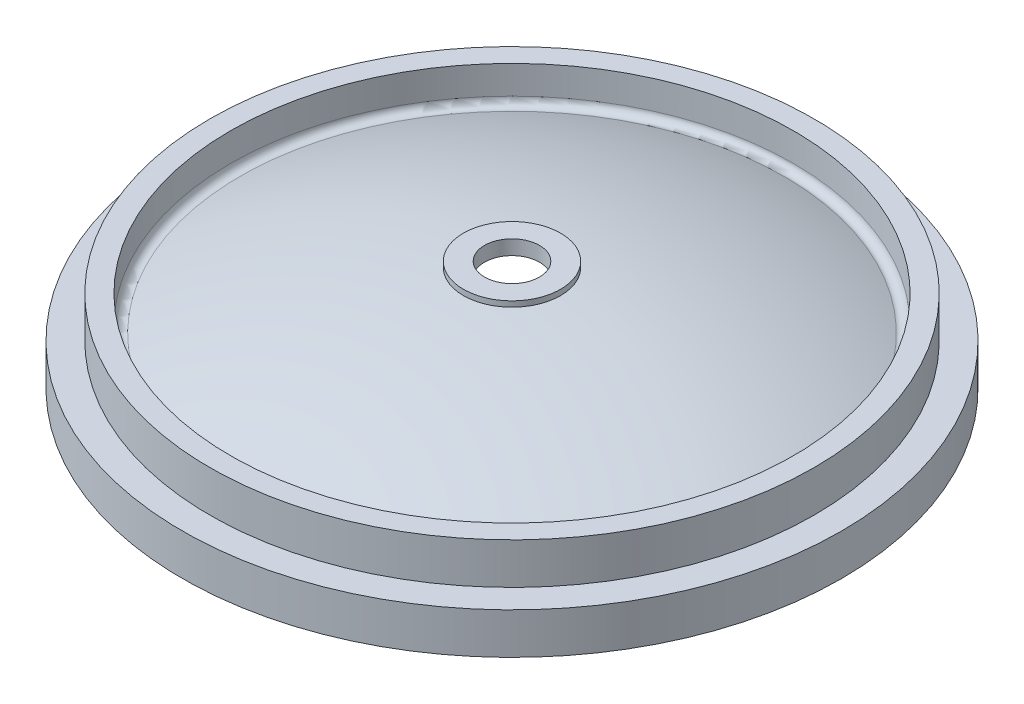
from build123d import *

# Parameters (mm, degrees)
FILLET1_R = 3.175
HOLE1_D   = 25.4


with BuildPart() as part:
    # Sketch1 → Revolve1 (revolve)
    with BuildSketch(Plane.XY):
        with BuildLine():
            Line((0, 50.922456672), (0, 44.45))
            ThreePointArc((0, 44.45), (76.487596697, 34.257888417), (147.6375, 4.392811034))
            Line((147.6375, 4.392811034), (147.6375, 0))
            Line((147.6375, 0), (152.4, 0))
            Line((152.4, 0), (152.4, 19.05))
            Line((152.4, 19.05), (139.7, 19.05))
            Line((139.7, 19.05), (139.7, 38.1))
            Line((139.7, 38.1), (130.175, 38.1))
            Line((130.175, 38.1), (130.175, 20.016399419))
            ThreePointArc((130.175, 20.016399419), (77.633557371, 39.159969489), (22.479, 48.382456672))
            Line((22.479, 48.382456672), (22.479, 50.922456672))
            Line((22.479, 50.922456672), (0, 50.922456672))
        make_face()
    revolve(axis=Axis((0, 50.922456672, 0), (0, -1, 0)))

    # Fillet1
    fillet1_edges = [part.edges().sort_by_distance(p)[0] for p in [
        (-130.175, 20.016399419, 0),
    ]]
    fillet(fillet1_edges, radius=FILLET1_R)

    # Hole1 (through all)
    with Locations(Plane(origin=(0, 50.922456672, 0), x_dir=(1, 0, 0), z_dir=(0, 1, 0))):
        with Locations((0, 0)):
            Hole(HOLE1_D / 2)


solid = part.part
